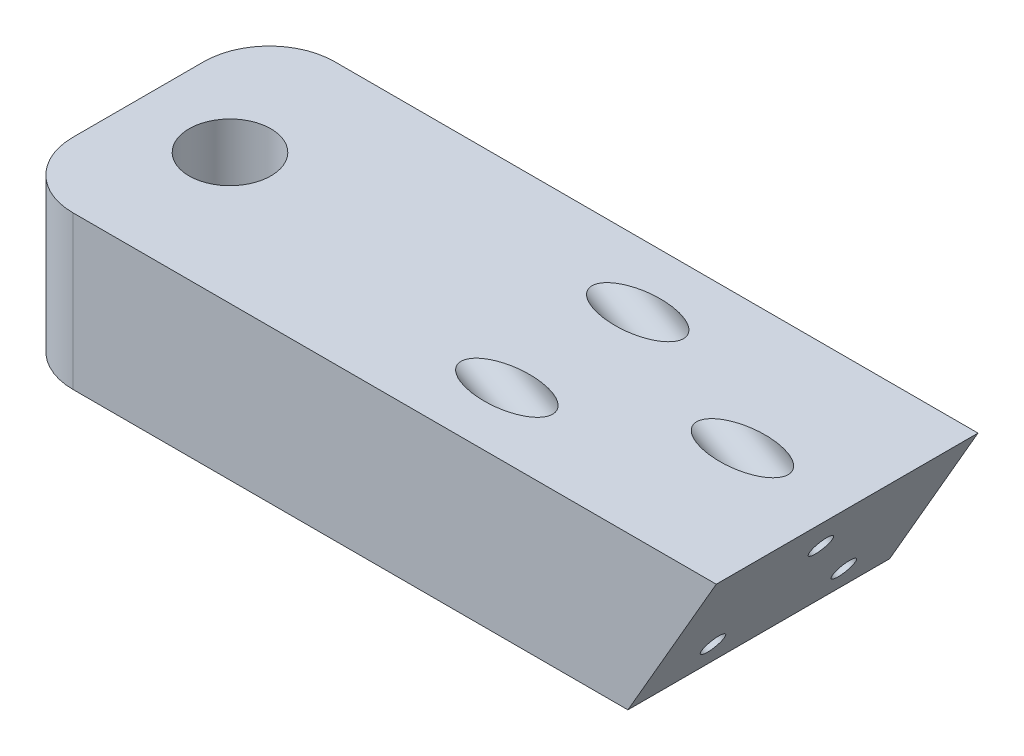
from build123d import *

# Parameters (mm, degrees)
SALIENTE_EXTRUIR1_DEPTH = 40
CORTAR_EXTRUIR1_REACH   = 25.383
CROQUIS2_R              = 6.25
REDONDEO1_R             = 10
CORTAR_EXTRUIR2_REACH   = 110.313
CROQUIS3_R              = 2.3
CORTAR_EXTRUIR3_REACH   = 95.802
CROQUIS4_R              = 1.75
CORTAR_EXTRUIR4_REACH   = 89.802
CROQUIS5_R              = 3.5


with BuildPart() as part:
    # Croquis1 → Saliente-Extruir1 (new body)
    with BuildSketch(Plane.XY):
        Polygon((80.813466521, 8.767949192), (-13.999287239, 8.767949192), (-13.999287239, 32.150635095), (94.313466521, 32.150635095), align=None)
    extrude(amount=SALIENTE_EXTRUIR1_DEPTH)

    # Croquis2 → Cortar-Extruir1 (cut, up to next)
    with BuildSketch(Plane(origin=(0, 32.150635095, 0), x_dir=(1, 0, 0), z_dir=(0, 1, 0)), mode=Mode.PRIVATE) as cortar_extruir1_sk1:
        with Locations((0, -20)):
            Circle(CROQUIS2_R)
    cortar_extruir1_tool1 = extrude(cortar_extruir1_sk1.sketch, amount=-CORTAR_EXTRUIR1_REACH, mode=Mode.PRIVATE) & part.part
    add(cortar_extruir1_tool1.solids().sort_by_distance((0, 32.150635, 20))[0], mode=Mode.SUBTRACT)

    # Redondeo1
    redondeo1_edges = [part.edges().sort_by_distance(p)[0] for p in [
        (-13.999287239, 20.459292144, 0),
        (-13.999287239, 20.459292144, 40),
    ]]
    fillet(redondeo1_edges, radius=REDONDEO1_R)

    # Croquis3 → Cortar-Extruir2 (cut, up to next)
    with BuildSketch(Plane.ZY.offset(13.999287239), mode=Mode.PRIVATE) as cortar_extruir2_sk1:
        with Locations((20, 20.150635095)):
            Circle(CROQUIS3_R)
    cortar_extruir2_tool1 = extrude(cortar_extruir2_sk1.sketch, amount=-CORTAR_EXTRUIR2_REACH, mode=Mode.PRIVATE) & part.part
    add(cortar_extruir2_tool1.solids().sort_by_distance((-13.999287, 20.150635, 20))[0], mode=Mode.SUBTRACT)

    # Croquis4 → Cortar-Extruir3 (cut, up to next)
    with BuildSketch(Plane(origin=(56.813466521, -32.801270189, 0), x_dir=(0, 0, -1), z_dir=(0.866025404, -0.5, 0)), mode=Mode.PRIVATE) as cortar_extruir3_sk1:
        with Locations((-30, 54)):
            Circle(CROQUIS4_R)
    cortar_extruir3_tool1 = extrude(cortar_extruir3_sk1.sketch, amount=-CORTAR_EXTRUIR3_REACH, mode=Mode.PRIVATE) & part.part
    add(cortar_extruir3_tool1.solids().sort_by_distance((83.813467, 13.964102, 30))[0], mode=Mode.SUBTRACT)
    # Croquis4 → Cortar-Extruir3 (cut, up to next)
    with BuildSketch(Plane(origin=(56.813466521, -32.801270189, 0), x_dir=(0, 0, -1), z_dir=(0.866025404, -0.5, 0)), mode=Mode.PRIVATE) as cortar_extruir3_sk2:
        with Locations((-10, 54)):
            Circle(CROQUIS4_R)
    cortar_extruir3_tool2 = extrude(cortar_extruir3_sk2.sketch, amount=-CORTAR_EXTRUIR3_REACH, mode=Mode.PRIVATE) & part.part
    add(cortar_extruir3_tool2.solids().sort_by_distance((83.813467, 13.964102, 10))[0], mode=Mode.SUBTRACT)
    # Croquis4 → Cortar-Extruir3 (cut, up to next)
    with BuildSketch(Plane(origin=(56.813466521, -32.801270189, 0), x_dir=(0, 0, -1), z_dir=(0.866025404, -0.5, 0)), mode=Mode.PRIVATE) as cortar_extruir3_sk3:
        with Locations((-20, 67)):
            Circle(CROQUIS4_R)
    cortar_extruir3_tool3 = extrude(cortar_extruir3_sk3.sketch, amount=-CORTAR_EXTRUIR3_REACH, mode=Mode.PRIVATE) & part.part
    add(cortar_extruir3_tool3.solids().sort_by_distance((90.313467, 25.222432, 20))[0], mode=Mode.SUBTRACT)

    # Croquis5 → Cortar-Extruir4 (cut, up to next)
    with BuildSketch(Plane(origin=(51.617314098, -29.801270189, 0), x_dir=(0, 0, -1), z_dir=(0.866025404, -0.5, 0)), mode=Mode.PRIVATE) as cortar_extruir4_sk1:
        with Locations((-30, 54)):
            Circle(CROQUIS5_R)
    cortar_extruir4_tool1 = extrude(cortar_extruir4_sk1.sketch, amount=-CORTAR_EXTRUIR4_REACH, mode=Mode.PRIVATE) & part.part
    add(cortar_extruir4_tool1.solids().sort_by_distance((78.617314, 16.964102, 30))[0], mode=Mode.SUBTRACT)
    # Croquis5 → Cortar-Extruir4 (cut, up to next)
    with BuildSketch(Plane(origin=(51.617314098, -29.801270189, 0), x_dir=(0, 0, -1), z_dir=(0.866025404, -0.5, 0)), mode=Mode.PRIVATE) as cortar_extruir4_sk2:
        with Locations((-20, 67)):
            Circle(CROQUIS5_R)
    cortar_extruir4_tool2 = extrude(cortar_extruir4_sk2.sketch, amount=-CORTAR_EXTRUIR4_REACH, mode=Mode.PRIVATE) & part.part
    add(cortar_extruir4_tool2.solids().sort_by_distance((85.117314, 28.222432, 20))[0], mode=Mode.SUBTRACT)
    # Croquis5 → Cortar-Extruir4 (cut, up to next)
    with BuildSketch(Plane(origin=(51.617314098, -29.801270189, 0), x_dir=(0, 0, -1), z_dir=(0.866025404, -0.5, 0)), mode=Mode.PRIVATE) as cortar_extruir4_sk3:
        with Locations((-10, 54)):
            Circle(CROQUIS5_R)
    cortar_extruir4_tool3 = extrude(cortar_extruir4_sk3.sketch, amount=-CORTAR_EXTRUIR4_REACH, mode=Mode.PRIVATE) & part.part
    add(cortar_extruir4_tool3.solids().sort_by_distance((78.617314, 16.964102, 10))[0], mode=Mode.SUBTRACT)


solid = part.part
